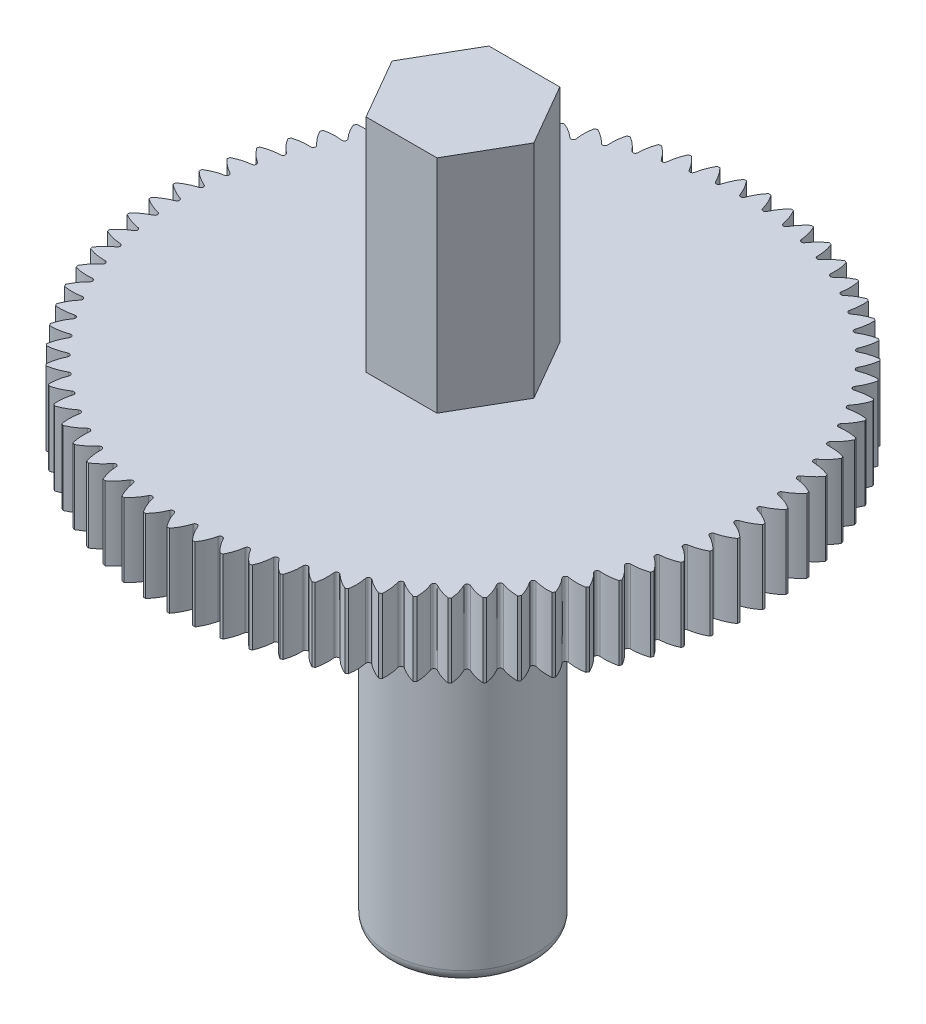
from build123d import *

# Parameters (mm, degrees)
FILLET1_R          = 0.5
SKETCH2_OUTSIDE_W  = 34.928
SKETCH2_OUTSIDE_H  = 34.928
CUT_EXTRUDE1_DEPTH = 9
CUT_EXTRUDE2_DEPTH = 9
CIRPATTERN1_COUNT  = 75


with BuildPart() as part:
    # Sketch1 → Revolve1 (revolve)
    with BuildSketch(Plane.XY):
        Polygon((0, 0), (0, 29), (3, 29), (3, 20), (12, 20), (12, 17), (3, 17), (3, 0), align=None)
    revolve(axis=Axis((0, 0, 0), (0, 1, 0)))

    # Fillet1
    fillet1_edges = [part.edges().sort_by_distance(p)[0] for p in [
        (-3, 0, 0),
    ]]
    fillet(fillet1_edges, radius=FILLET1_R)

    # Sketch2 outside → Cut-Extrude1 (cut)
    with BuildSketch(Plane(origin=(0, 29, 0), x_dir=(1, 0, 0), z_dir=(0, 1, 0))):
        Rectangle(SKETCH2_OUTSIDE_W, SKETCH2_OUTSIDE_H)
        Polygon((1.443375673, 2.5), (-1.443375673, 2.5), (-2.886751346, 0), (-1.443375673, -2.5), (1.443375673, -2.5), (2.886751346, 0), align=None, mode=Mode.SUBTRACT)
    extrude(amount=-CUT_EXTRUDE1_DEPTH, mode=Mode.SUBTRACT)

    # Sketch3 → Cut-Extrude2 (cut)
    with BuildSketch(Plane(origin=(0, 20, 0), x_dir=(1, 0, 0), z_dir=(0, 1, 0))):
        with BuildLine():
            Line((-41.745256274, 60.963736912), (-0.45, 11.991559532))
            ThreePointArc((-0.45, 11.991559532), (-0.244185037, 11.69752696), (-0.094236566, 11.371443523))
            ThreePointArc((-0.094236566, 11.371443523), (0, 11.304902), (0.094236566, 11.371443523))
            ThreePointArc((0.094236566, 11.371443523), (0.244185037, 11.69752696), (0.45, 11.991559532))
            Line((0.45, 11.991559532), (41.745256274, 60.963736912))
            Line((41.745256274, 60.963736912), (41.745256274, 189.082000217))
            Line((41.745256274, 189.082000217), (-41.745256274, 189.082000217))
            Line((-41.745256274, 189.082000217), (-41.745256274, 60.963736912))
        make_face()
    cut_extrude2 = extrude(amount=-CUT_EXTRUDE2_DEPTH, mode=Mode.SUBTRACT)

    # CirPattern1: Cut-Extrude2 ×75 about axis
    cirpattern1_axis = Axis((0, 0, 0), (0, 1, 0))
    for i in range(1, CIRPATTERN1_COUNT):
        add(cut_extrude2.rotate(cirpattern1_axis, i * 360 / CIRPATTERN1_COUNT), mode=Mode.SUBTRACT)


solid = part.part
